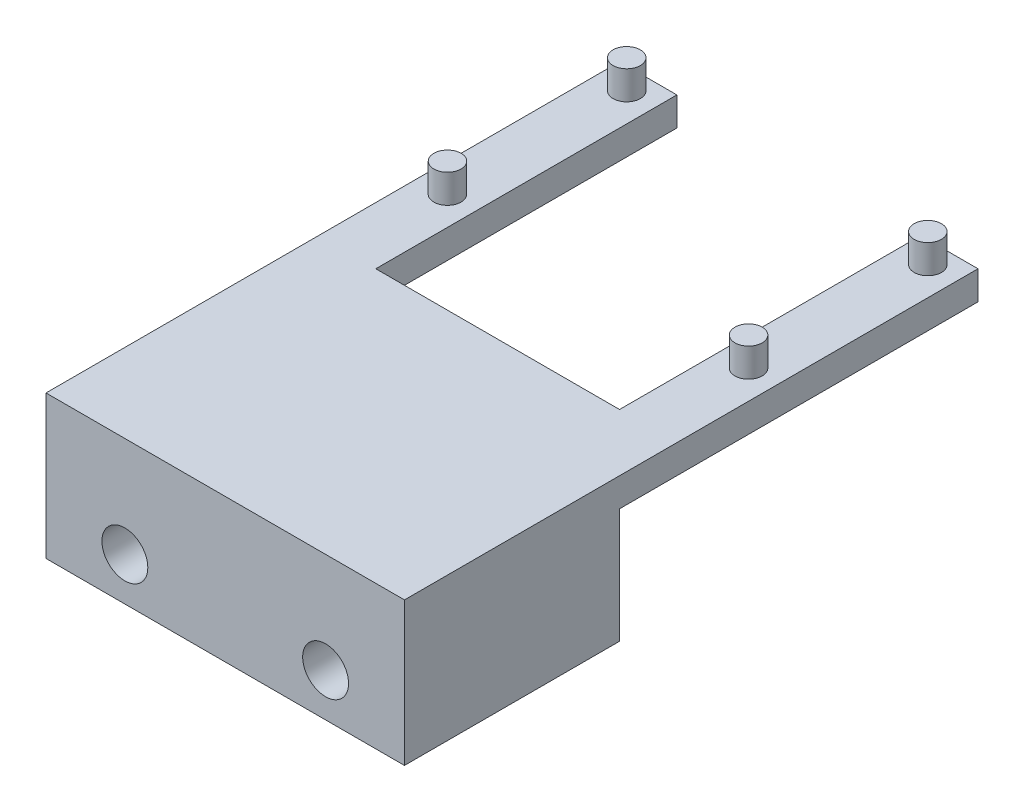
from build123d import *

# Parameters (mm, degrees)
BOSS_EXTRUDE1_DEPTH = 2
SKETCH2_R           = 0.95
BOSS_EXTRUDE2_DEPTH = 2
SKETCH3_W           = 25
SKETCH3_H           = 10
BOSS_EXTRUDE3_DEPTH = 15
SKETCH4_R           = 1.6
CUT_EXTRUDE1_DEPTH  = 20


with BuildPart() as part:
    # Sketch1 → Boss-Extrude1 (new body)
    with BuildSketch(Plane(origin=(0, 0, 0), x_dir=(1, 0, 0), z_dir=(0, 1, 0))):
        Polygon((-8.5, 12.5), (-8.5, -8.5), (8.5, -8.5), (8.5, 12.5), (12.5, 12.5), (12.5, -12.5), (-12.5, -12.5), (-12.5, 12.5), align=None)
    extrude(amount=BOSS_EXTRUDE1_DEPTH)

    # Sketch2 → Boss-Extrude2 (add)
    with BuildSketch(Plane(origin=(0, 2, 0), x_dir=(1, 0, 0), z_dir=(0, 1, 0))):
        with Locations((-10.5, 11)):
            Circle(SKETCH2_R)
        with Locations((-10.5, -1.5)):
            Circle(SKETCH2_R)
        with Locations((10.5, 11)):
            Circle(SKETCH2_R)
        with Locations((10.5, -1.5)):
            Circle(SKETCH2_R)
    extrude(amount=BOSS_EXTRUDE2_DEPTH)

    # Sketch3 → Boss-Extrude3 (add)
    with BuildSketch(Plane.XY.offset(12.5)):
        with Locations((0, -3)):
            Rectangle(SKETCH3_W, SKETCH3_H)
    extrude(amount=BOSS_EXTRUDE3_DEPTH)

    # Sketch4 → Cut-Extrude1 (cut)
    with BuildSketch(Plane.XY.offset(27.5)):
        with Locations((-7, -5)):
            Circle(SKETCH4_R)
        with Locations((7, -5)):
            Circle(SKETCH4_R)
    extrude(amount=-CUT_EXTRUDE1_DEPTH, mode=Mode.SUBTRACT)


solid = part.part
